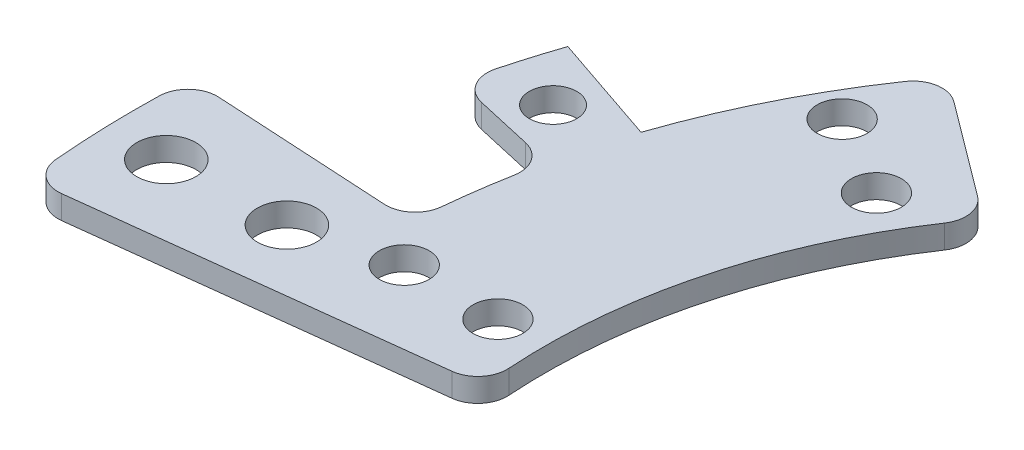
from build123d import *

# Parameters (mm, degrees)
SKETCH1_R               = 2.125
BOSS_EXTRUDE1_DEPTH     = 2
BOSS_EXTRUDE3_DEPTH     = 2
SKETCH4_R               = 2.025
CUT_EXTRUDE1_DEPTH      = 1
CUT_EXTRUDE1_DEPTH_BACK = 3
SKETCH6_R               = 2.525
BOSS_EXTRUDE4_DEPTH     = 2
FILLET1_R               = 2.5


with BuildPart() as part:
    # Sketch1 → Boss-Extrude1 (new body)
    with BuildSketch(Plane(origin=(0, 0, 0), x_dir=(1, 0, 0), z_dir=(0, 1, 0))):
        with BuildLine():
            Line((-37.655823606, 28.125414637), (-49.673639651, 37.101610798))
            ThreePointArc((-49.673639651, 37.101610798), (-59.88740123, 16.046780796), (-61.569439235, -7.294117647))
            Line((-61.569439235, -7.294117647), (-46.673607162, -5.529411765))
            ThreePointArc((-46.673607162, -5.529411765), (-45.398513836, 12.16449512), (-37.655823606, 28.125414637))
        make_face()
        with Locations((-44.167295593, 25.5)):
            Circle(SKETCH1_R, mode=Mode.SUBTRACT)
        with Locations((-51.095498823, 29.5)):
            Circle(SKETCH1_R, mode=Mode.SUBTRACT)
        with Locations((-59, 0)):
            Circle(SKETCH1_R, mode=Mode.SUBTRACT)
        with Locations((-51, 0)):
            Circle(SKETCH1_R, mode=Mode.SUBTRACT)
    extrude(amount=BOSS_EXTRUDE1_DEPTH)

    # Sketch3 → Boss-Extrude3 (add)
    with BuildSketch(Plane(origin=(0, 0, 0), x_dir=(1, 0, 0), z_dir=(0, 1, 0))):
        with BuildLine():
            Line((-70.222891931, 15.897969958), (-60.469712497, 13.689918575))
            ThreePointArc((-60.469712497, 13.689918575), (-59.670365878, 16.835897245), (-58.707466934, 19.93572989))
            Line((-58.707466934, 19.93572989), (-68.176413213, 23.151170195))
            ThreePointArc((-68.176413213, 23.151170195), (-69.294618439, 19.551364542), (-70.222891931, 15.897969958))
        make_face()
    extrude(amount=BOSS_EXTRUDE3_DEPTH)

    # Sketch4 → Cut-Extrude1 (cut, two sides)
    with BuildSketch(Plane(origin=(0, 2, 0), x_dir=(1, 0, 0), z_dir=(0, 1, 0))) as cut_extrude1_sk:
        with Locations((-64.482492158, 18.193630893)):
            Circle(SKETCH4_R)
    extrude(amount=CUT_EXTRUDE1_DEPTH, mode=Mode.SUBTRACT)
    extrude(cut_extrude1_sk.sketch, amount=-CUT_EXTRUDE1_DEPTH_BACK, mode=Mode.SUBTRACT)

    # Sketch6 → Boss-Extrude4 (add)
    with BuildSketch(Plane(origin=(0, 0, 0), x_dir=(1, 0, 0), z_dir=(0, 1, 0))):
        with BuildLine():
            Line((-61.569439235, -7.294117647), (-81.430548666, -9.647058824))
            ThreePointArc((-81.430548666, -9.647058824), (-81.961477421, -2.513208901), (-81.868629843, 4.639768059))
            Line((-81.868629843, 4.639768059), (-61.900671345, 3.508117313))
            ThreePointArc((-61.900671345, 3.508117313), (-61.970873172, -1.90023112), (-61.569439235, -7.294117647))
        make_face()
        with Locations((-76.963826359, -2.359964456)):
            Circle(SKETCH6_R, mode=Mode.SUBTRACT)
        with Locations((-66.968524234, -2.053475565)):
            Circle(SKETCH6_R, mode=Mode.SUBTRACT)
    extrude(amount=BOSS_EXTRUDE4_DEPTH)

    # Fillet1
    fillet1_edges = [part.edges().sort_by_distance(p)[0] for p in [
        (-60.469712497, 1, -13.689918575),
        (-70.222891931, 1, -15.897969958),
        (-81.430548666, 1, 9.647058824),
        (-81.868629843, 1, -4.639768059),
        (-61.900671345, 1, -3.508117313),
        (-46.673607162, 1, 5.529411765),
        (-49.673639651, 1, -37.101610798),
        (-37.655823606, 1, -28.125414637),
    ]]
    fillet(fillet1_edges, radius=FILLET1_R)


solid = part.part
